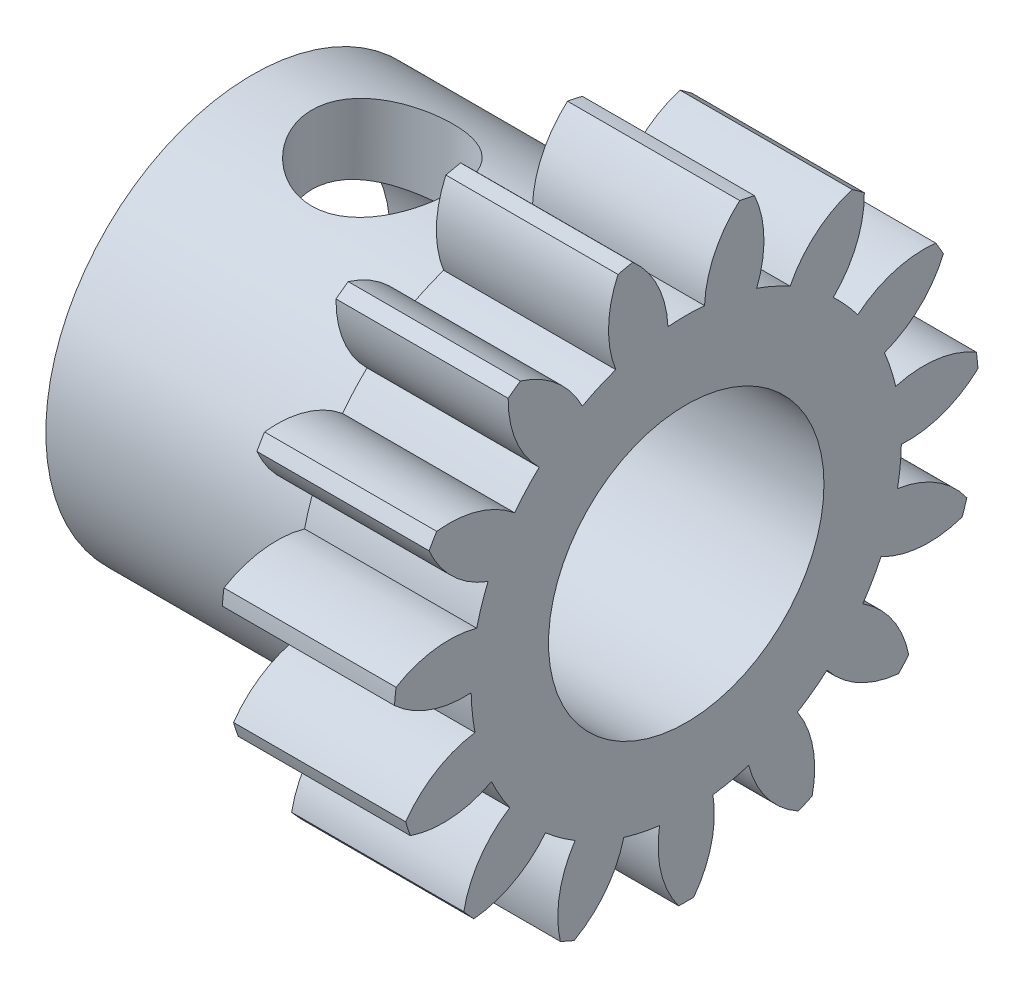
from build123d import *

# Parameters (mm, degrees)
SKETCH1_W                          = 2.5
SKETCH1_H                          = 4.25
CUT_EXTRUDE1_DEPTH                 = 3.5
CUT_EXTRUDE2_DEPTH                 = 3.5
CUT_EXTRUDE3_DEPTH                 = 3.5
CUT_EXTRUDE4_DEPTH                 = 3.5
CUT_EXTRUDE5_DEPTH                 = 3.5
CUT_EXTRUDE6_DEPTH                 = 3.5
CUT_EXTRUDE7_DEPTH                 = 3.5
CUT_EXTRUDE8_DEPTH                 = 3.5
CUT_EXTRUDE9_DEPTH                 = 3.5
CUT_EXTRUDE10_DEPTH                = 3.5
CUT_EXTRUDE11_DEPTH                = 3.5
CUT_EXTRUDE12_DEPTH                = 3.5
CUT_EXTRUDE13_DEPTH                = 3.5
CUT_EXTRUDE14_DEPTH                = 3.5
CUT_EXTRUDE15_DEPTH                = 3.5
SKETCH17_W                         = 3.8000508
SKETCH17_H                         = 3
F_4_0_4_DIAMETER_HOLE1_D           = 4
F_4_0_4_DIAMETER_HOLE1_DEPTH       = 6.3000508
TAP_DRILL_FOR_M2_5X0_45_TAP1_D     = 2.05
TAP_DRILL_FOR_M2_5X0_45_TAP1_DEPTH = 6


with BuildPart() as part:
    # Sketch1 → Revolve1 (revolve)
    with BuildSketch(Plane(origin=(0, 0, 0), x_dir=(-1, 0, 0), z_dir=(0, 0, -1))):
        with Locations((-1.25, 2.125)):
            Rectangle(SKETCH1_W, SKETCH1_H)
    revolve(axis=Axis((2.5, 0, 0), (-1, 0, 0)))

    # Sketch2 → Cut-Extrude1 (cut, through all)
    with BuildSketch(Plane(origin=(2.5, 0, 0), x_dir=(0, 0, -1), z_dir=(1, 0, 0))):
        with BuildLine():
            ThreePointArc((2.585993953, 3.372704445), (2.472774023, 2.780247912), (2.135335156, 2.280289405))
            ThreePointArc((2.135335156, 2.280289405), (2.321584435, 2.090364014), (2.491001044, 1.88528242))
            ThreePointArc((2.491001044, 1.88528242), (3.023492692, 2.168612866), (3.624538392, 2.219283994))
            ThreePointArc((3.624538392, 2.219283994), (3.158365508, 2.843805077), (2.585993953, 3.372704445))
        make_face()
    extrude(amount=-CUT_EXTRUDE1_DEPTH, mode=Mode.SUBTRACT)

    # Sketch3 → Cut-Extrude2 (cut, through all)
    with BuildSketch(Plane(origin=(2.5, 0, 0), x_dir=(0, 0, -1), z_dir=(1, 0, 0))):
        with BuildLine():
            ThreePointArc((3.734225512, 2.029300328), (3.389820178, 1.534115047), (2.87820299, 1.214628975))
            ThreePointArc((2.87820299, 1.214628975), (2.971100557, 0.96536909), (3.042456131, 0.709109787))
            ThreePointArc((3.042456131, 0.709109787), (3.644152332, 0.751361165), (4.213844705, 0.553184234))
            ThreePointArc((4.213844705, 0.553184234), (4.041990194, 1.313322226), (3.734225512, 2.029300328))
        make_face()
    extrude(amount=-CUT_EXTRUDE2_DEPTH, mode=Mode.SUBTRACT)

    # Sketch4 → Cut-Extrude3 (cut, through all)
    with BuildSketch(Plane(origin=(2.5, 0, 0), x_dir=(0, 0, -1), z_dir=(1, 0, 0))):
        with BuildLine():
            ThreePointArc((4.236775558, 0.335011746), (3.72073563, 0.022719752), (3.12340338, -0.061051839))
            ThreePointArc((3.12340338, -0.061051839), (3.106886401, -0.326546919), (3.067842913, -0.589674367))
            ThreePointArc((3.067842913, -0.589674367), (3.634704928, -0.795807707), (4.074538988, -1.208566106))
            ThreePointArc((4.074538988, -1.208566106), (4.226718055, -0.444245969), (4.236775558, 0.335011746))
        make_face()
    extrude(amount=-CUT_EXTRUDE3_DEPTH, mode=Mode.SUBTRACT)

    # Sketch5 → Cut-Extrude4 (cut, through all)
    with BuildSketch(Plane(origin=(2.5, 0, 0), x_dir=(0, 0, -1), z_dir=(1, 0, 0))):
        with BuildLine():
            ThreePointArc((4.00674862, -1.417203408), (3.40830209, -1.492603993), (2.82853895, -1.326176235))
            ThreePointArc((2.82853895, -1.326176235), (2.705463361, -1.562), (2.562771785, -1.786498468))
            ThreePointArc((2.562771785, -1.786498468), (2.996784021, -2.205374197), (3.230708464, -2.761344386))
            ThreePointArc((3.230708464, -2.761344386), (3.680607966, -2.124999999), (4.00674862, -1.417203408))
        make_face()
    extrude(amount=-CUT_EXTRUDE4_DEPTH, mode=Mode.SUBTRACT)

    # Sketch6 → Cut-Extrude5 (cut, through all)
    with BuildSketch(Plane(origin=(2.5, 0, 0), x_dir=(0, 0, -1), z_dir=(1, 0, 0))):
        with BuildLine():
            ThreePointArc((3.083918444, -2.92437122), (2.506542154, -2.749842949), (2.044594439, -2.361992714))
            ThreePointArc((2.044594439, -2.361992714), (1.836241128, -2.52736909), (1.614574134, -2.674420753))
            ThreePointArc((1.614574134, -2.674420753), (1.840691933, -3.233611452), (1.828259097, -3.836661137))
            ThreePointArc((1.828259097, -3.836661137), (2.498087322, -3.438322226), (3.083918444, -2.92437122))
        make_face()
    extrude(amount=-CUT_EXTRUDE5_DEPTH, mode=Mode.SUBTRACT)

    # Sketch7 → Cut-Extrude6 (cut, through all)
    with BuildSketch(Plane(origin=(2.5, 0, 0), x_dir=(0, 0, -1), z_dir=(1, 0, 0))):
        with BuildLine():
            ThreePointArc((1.627850754, -3.925888679), (1.17137831, -3.531609077), (0.907120976, -2.989399193))
            ThreePointArc((0.907120976, -2.989399193), (0.649516122, -3.055733105), (0.387201946, -3.099911394))
            ThreePointArc((0.387201946, -3.099911394), (0.366327487, -3.702727912), (0.109687121, -4.248584321))
            ThreePointArc((0.109687121, -4.248584321), (0.883624686, -4.157127303), (1.627850754, -3.925888679))
        make_face()
    extrude(amount=-CUT_EXTRUDE6_DEPTH, mode=Mode.SUBTRACT)

    # Sketch8 → Cut-Extrude7 (cut, through all)
    with BuildSketch(Plane(origin=(2.5, 0, 0), x_dir=(0, 0, -1), z_dir=(1, 0, 0))):
        with BuildLine():
            ThreePointArc((-0.109687122, -4.248584322), (-0.366327487, -3.702727912), (-0.387201947, -3.099911394))
            ThreePointArc((-0.387201947, -3.099911394), (-0.649516122, -3.055733105), (-0.907120975, -2.989399193))
            ThreePointArc((-0.907120975, -2.989399193), (-1.171378309, -3.531609077), (-1.627850753, -3.92588868))
            ThreePointArc((-1.627850753, -3.92588868), (-0.883624686, -4.157127304), (-0.109687122, -4.248584322))
        make_face()
    extrude(amount=-CUT_EXTRUDE7_DEPTH, mode=Mode.SUBTRACT)

    # Sketch9 → Cut-Extrude8 (cut, through all)
    with BuildSketch(Plane(origin=(2.5, 0, 0), x_dir=(0, 0, -1), z_dir=(1, 0, 0))):
        with BuildLine():
            ThreePointArc((-1.828259096, -3.836661137), (-1.840691932, -3.233611453), (-1.614574133, -2.674420754))
            ThreePointArc((-1.614574133, -2.674420754), (-1.836241128, -2.527369091), (-2.044594439, -2.361992714))
            ThreePointArc((-2.044594439, -2.361992714), (-2.506542155, -2.749842949), (-3.083918444, -2.92437122))
            ThreePointArc((-3.083918444, -2.92437122), (-2.498087322, -3.438322226), (-1.828259096, -3.836661137))
        make_face()
    extrude(amount=-CUT_EXTRUDE8_DEPTH, mode=Mode.SUBTRACT)

    # Sketch10 → Cut-Extrude9 (cut, through all)
    with BuildSketch(Plane(origin=(2.5, 0, 0), x_dir=(0, 0, -1), z_dir=(1, 0, 0))):
        with BuildLine():
            ThreePointArc((-3.230708464, -2.761344387), (-2.996784021, -2.205374197), (-2.562771785, -1.786498468))
            ThreePointArc((-2.562771785, -1.786498468), (-2.705463361, -1.562), (-2.82853895, -1.326176236))
            ThreePointArc((-2.82853895, -1.326176236), (-3.40830209, -1.492603994), (-4.006748619, -1.417203409))
            ThreePointArc((-4.006748619, -1.417203409), (-3.680607966, -2.125), (-3.230708464, -2.761344387))
        make_face()
    extrude(amount=-CUT_EXTRUDE9_DEPTH, mode=Mode.SUBTRACT)

    # Sketch11 → Cut-Extrude10 (cut, through all)
    with BuildSketch(Plane(origin=(2.5, 0, 0), x_dir=(0, 0, -1), z_dir=(1, 0, 0))):
        with BuildLine():
            ThreePointArc((-4.074538989, -1.208566105), (-3.634704928, -0.795807707), (-3.067842914, -0.589674368))
            ThreePointArc((-3.067842914, -0.589674368), (-3.106886402, -0.326546919), (-3.12340338, -0.061051839))
            ThreePointArc((-3.12340338, -0.061051839), (-3.720735631, 0.022719752), (-4.236775558, 0.335011747))
            ThreePointArc((-4.236775558, 0.335011747), (-4.226718056, -0.444245968), (-4.074538989, -1.208566105))
        make_face()
    extrude(amount=-CUT_EXTRUDE10_DEPTH, mode=Mode.SUBTRACT)

    # Sketch12 → Cut-Extrude11 (cut, through all)
    with BuildSketch(Plane(origin=(2.5, 0, 0), x_dir=(0, 0, -1), z_dir=(1, 0, 0))):
        with BuildLine():
            ThreePointArc((-4.213844706, 0.553184234), (-3.644152332, 0.751361165), (-3.042456131, 0.709109788))
            ThreePointArc((-3.042456131, 0.709109788), (-2.971100557, 0.96536909), (-2.87820299, 1.214628975))
            ThreePointArc((-2.87820299, 1.214628975), (-3.389820179, 1.534115046), (-3.734225513, 2.029300326))
            ThreePointArc((-3.734225513, 2.029300326), (-4.041990195, 1.313322226), (-4.213844706, 0.553184234))
        make_face()
    extrude(amount=-CUT_EXTRUDE11_DEPTH, mode=Mode.SUBTRACT)

    # Sketch13 → Cut-Extrude12 (cut, through all)
    with BuildSketch(Plane(origin=(2.5, 0, 0), x_dir=(0, 0, -1), z_dir=(1, 0, 0))):
        with BuildLine():
            ThreePointArc((-2.585993952, 3.372704446), (-3.158365508, 2.843805077), (-3.624538391, 2.219283994))
            ThreePointArc((-3.624538391, 2.219283994), (-3.023492692, 2.168612865), (-2.491001044, 1.885282419))
            ThreePointArc((-2.491001044, 1.885282419), (-2.321584435, 2.090364014), (-2.135335156, 2.280289405))
            ThreePointArc((-2.135335156, 2.280289405), (-2.472774022, 2.780247912), (-2.585993952, 3.372704446))
        make_face()
    extrude(amount=-CUT_EXTRUDE12_DEPTH, mode=Mode.SUBTRACT)

    # Sketch14 → Cut-Extrude13 (cut, through all)
    with BuildSketch(Plane(origin=(2.5, 0, 0), x_dir=(0, 0, -1), z_dir=(1, 0, 0))):
        with BuildLine():
            ThreePointArc((-0.990620545, 4.132937326), (-1.728630733, 3.882568195), (-2.408516462, 3.501649391))
            ThreePointArc((-2.408516462, 3.501649391), (-1.880043697, 3.210891701), (-1.508829246, 2.735472593))
            ThreePointArc((-1.508829246, 2.735472593), (-1.270645273, 2.85391601), (-1.023248474, 2.951667081))
            ThreePointArc((-1.023248474, 2.951667081), (-1.128162774, 3.545650656), (-0.990620545, 4.132937326))
        make_face()
    extrude(amount=-CUT_EXTRUDE13_DEPTH, mode=Mode.SUBTRACT)

    # Sketch15 → Cut-Extrude14 (cut, through all)
    with BuildSketch(Plane(origin=(2.5, 0, 0), x_dir=(0, 0, -1), z_dir=(1, 0, 0))):
        with BuildLine():
            ThreePointArc((-0.776040155, 4.178547795), (-0.411518069, 3.69797819), (-0.265767165, 3.112674704))
            ThreePointArc((-0.265767165, 3.112674704), (0, 3.124), (0.265767165, 3.112674704))
            ThreePointArc((0.265767165, 3.112674704), (0.411518069, 3.69797819), (0.776040156, 4.178547795))
            ThreePointArc((0.776040156, 4.178547795), (0, 4.25), (-0.776040155, 4.178547795))
        make_face()
    extrude(amount=-CUT_EXTRUDE14_DEPTH, mode=Mode.SUBTRACT)

    # Sketch16 → Cut-Extrude15 (cut, through all)
    with BuildSketch(Plane(origin=(2.5, 0, 0), x_dir=(0, 0, -1), z_dir=(1, 0, 0))):
        with BuildLine():
            ThreePointArc((0.990620545, 4.132937326), (1.128162774, 3.545650656), (1.023248474, 2.951667081))
            ThreePointArc((1.023248474, 2.951667081), (1.270645273, 2.85391601), (1.508829246, 2.735472593))
            ThreePointArc((1.508829246, 2.735472593), (1.880043697, 3.210891701), (2.408516462, 3.50164939))
            ThreePointArc((2.408516462, 3.50164939), (1.728630733, 3.882568195), (0.990620545, 4.132937326))
        make_face()
    extrude(amount=-CUT_EXTRUDE15_DEPTH, mode=Mode.SUBTRACT)

    # Sketch17 → Revolve2 (revolve)
    with BuildSketch(Plane.XY):
        with Locations((-1.9000254, 1.5)):
            Rectangle(SKETCH17_W, SKETCH17_H)
    revolve(axis=Axis((-3.8000508, 0, 0), (1, 0, 0)))

    # Ø4.0 (4) Diameter Hole1
    with Locations(Plane(origin=(2.5, 0, 0), x_dir=(0, 0, -1), z_dir=(1, 0, 0))):
        with Locations((0, 0)):
            Hole(F_4_0_4_DIAMETER_HOLE1_D / 2, depth=F_4_0_4_DIAMETER_HOLE1_DEPTH)

    # Tap Drill for M2.5x0.45 Tap1
    with Locations(Plane(origin=(-1.9000508, 2.999970615, 0.013278053), x_dir=(0, -0.004426018, 0.999990205), z_dir=(0, 0.999990205, 0.004426018))):
        with Locations((0, 0)):
            Hole(TAP_DRILL_FOR_M2_5X0_45_TAP1_D / 2, depth=TAP_DRILL_FOR_M2_5X0_45_TAP1_DEPTH)


solid = part.part
